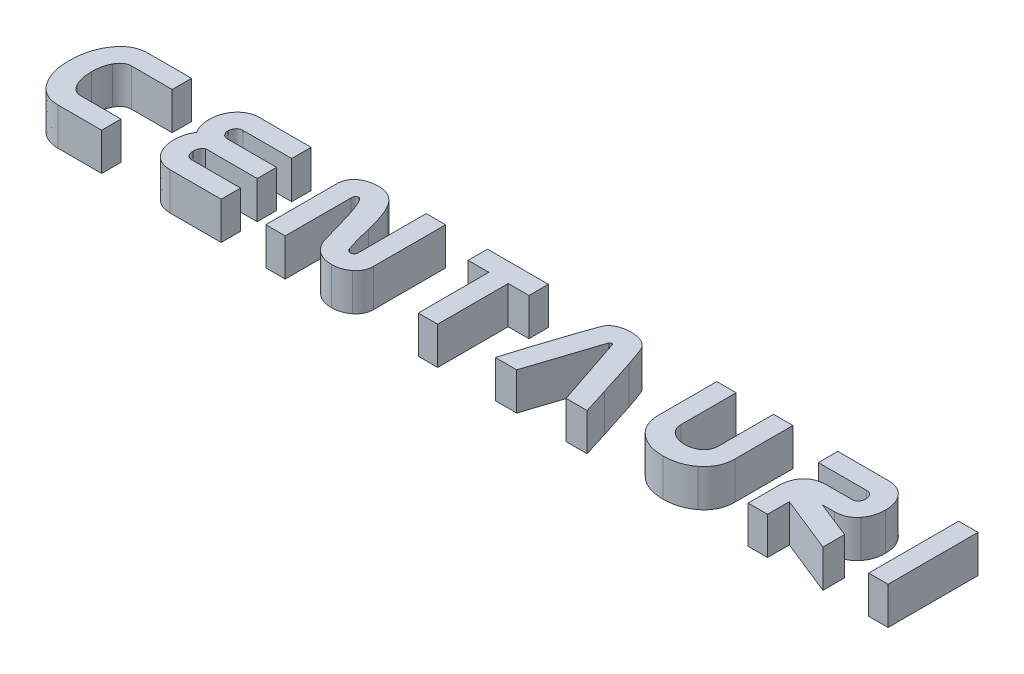
from build123d import *

# Parameters (mm, degrees)
BOSS_EXTRUDE1_DEPTH   = 5
BOSS_EXTRUDE1_2_DEPTH = 5
BOSS_EXTRUDE1_3_DEPTH = 5
BOSS_EXTRUDE1_4_DEPTH = 5
BOSS_EXTRUDE1_5_DEPTH = 5
BOSS_EXTRUDE1_6_DEPTH = 5
BOSS_EXTRUDE1_7_DEPTH = 5
SKETCH2_W             = 2.584615384
SKETCH2_H             = 12
BOSS_EXTRUDE1_8_DEPTH = 5


with BuildPart() as part:
    # Sketch2 → Boss-Extrude1 (new body)
    with BuildSketch(Plane(origin=(0, 0, 0), x_dir=(1, 0, 0), z_dir=(0, 1, 0))):
        with BuildLine():
            Line((10.583653846, 0), (4.771153846, 0))
            add(Edge.make_bspline(
                [(4.771153846, 0), (4.600577027, 0.005256158), (4.266744635, 0.015542878), (3.779986368, 0.104757843), (3.321676091, 0.249284117), (2.888640598, 0.44967442), (2.486608852, 0.712193), (2.110532552, 1.030628786), (1.76275976, 1.406766356), (1.562193503, 1.691748172), (1.459615385, 1.8375)],
                knots=[0, 0, 0, 0, 0.000511391, 0.001000833, 0.001478879, 0.00194992, 0.002427592, 0.002914759, 0.0034251, 0.003959346, 0.003959346, 0.003959346, 0.003959346], degree=3))
            add(Edge.make_bspline(
                [(1.459615385, 1.8375), (1.371116244, 1.977207082), (1.193250115, 2.257991257), (0.978414364, 2.711395344), (0.787404728, 3.18319021), (0.636476869, 3.68188656), (0.51388119, 4.202754443), (0.432733487, 4.748966419), (0.378460718, 5.317169459), (0.372344193, 5.704675421), (0.369230769, 5.901923077)],
                knots=[0, 0, 0, 0, 0.000495701, 0.000996263, 0.001502461, 0.002021636, 0.002557624, 0.003106345, 0.003676982, 0.004268581, 0.004268581, 0.004268581, 0.004268581], degree=3))
            add(Edge.make_bspline(
                [(0.369230769, 5.901923077), (0.372429228, 6.103000917), (0.378714753, 6.498153751), (0.431930375, 7.079155415), (0.517560051, 7.637252691), (0.638842238, 8.172274481), (0.794144014, 8.685947663), (0.988300396, 9.17489435), (1.212441088, 9.644085285), (1.39077351, 9.937917044), (1.479807692, 10.084615385)],
                knots=[0, 0, 0, 0, 0.000603133, 0.001185261, 0.001748677, 0.002295911, 0.002829721, 0.003356817, 0.003872873, 0.004387403, 0.004387403, 0.004387403, 0.004387403], degree=3))
            add(Edge.make_bspline(
                [(1.479807692, 10.084615385), (1.583180163, 10.237151582), (1.784074431, 10.533590735), (2.133573667, 10.925153122), (2.507077334, 11.258225235), (2.909264073, 11.528892198), (3.336322219, 11.742420666), (3.791773601, 11.892963089), (4.273222055, 11.984691886), (4.603438894, 11.994843873), (4.771153846, 12)],
                knots=[0, 0, 0, 0, 0.000552289, 0.00107332, 0.001569918, 0.002049953, 0.002523399, 0.00299774, 0.003484865, 0.003987616, 0.003987616, 0.003987616, 0.003987616], degree=3))
            Line((4.771153846, 12), (10.583653846, 12))
            Line((10.583653846, 12), (10.583653846, 9.415384615))
            Line((10.583653846, 9.415384615), (5.175, 9.415384615))
            add(Edge.make_bspline(
                [(5.175, 9.415384615), (5.095944201, 9.41167344), (4.940327859, 9.404368226), (4.712263849, 9.35787305), (4.496531906, 9.276902466), (4.296988942, 9.159047629), (4.108761042, 9.012682377), (3.93619572, 8.832200354), (3.77636789, 8.619553036), (3.684893689, 8.46162946), (3.6375, 8.379807692)],
                knots=[0, 0, 0, 0, 0.000237171, 0.000466856, 0.000695087, 0.000925152, 0.001159428, 0.001408309, 0.001671963, 0.001955435, 0.001955435, 0.001955435, 0.001955435], degree=3))
            add(Edge.make_bspline(
                [(3.6375, 8.379807692), (3.559310443, 8.218337814), (3.39818249, 7.885591194), (3.249544948, 7.331073915), (3.15507028, 6.725421927), (3.144145684, 6.303291404), (3.138461538, 6.083653846)],
                knots=[0, 0, 0, 0, 0.000537158, 0.001106941, 0.001714, 0.002372458, 0.002372458, 0.002372458, 0.002372458], degree=3))
            add(Edge.make_bspline(
                [(3.138461538, 6.083653846), (3.143678294, 5.85723427), (3.153765662, 5.419418574), (3.256034151, 4.789196535), (3.41020219, 4.205012741), (3.576462853, 3.850894878), (3.657692308, 3.677884615)],
                knots=[0, 0, 0, 0, 0.000678627, 0.001312225, 0.001911337, 0.002483662, 0.002483662, 0.002483662, 0.002483662], degree=3))
            add(Edge.make_bspline(
                [(3.657692308, 3.677884615), (3.704707297, 3.591043677), (3.795360914, 3.423598244), (3.958835405, 3.202191272), (4.12866677, 3.009880789), (4.315882401, 2.856678125), (4.512011351, 2.731914193), (4.723937386, 2.649145271), (4.945254612, 2.593907128), (5.097736923, 2.587740186), (5.175, 2.584615385)],
                knots=[0, 0, 0, 0, 0.000295895, 0.00057054, 0.000823762, 0.001063463, 0.001294016, 0.001517922, 0.001743218, 0.001974635, 0.001974635, 0.001974635, 0.001974635], degree=3))
            Line((5.175, 2.584615385), (10.583653846, 2.584615385))
            Line((10.583653846, 2.584615385), (10.583653846, 0))
        make_face()
    extrude(amount=BOSS_EXTRUDE1_DEPTH)


with BuildPart() as body_2:
    # Sketch2 → Boss-Extrude1 2 (new body)
    with BuildSketch(Plane(origin=(0, 0, 0), x_dir=(1, 0, 0), z_dir=(0, 1, 0))):
        with BuildLine():
            Line((26.534423077, 0), (19.726730769, 0))
            add(Edge.make_bspline(
                [(19.726730769, 0), (19.60248923, 0.002968336), (19.359459963, 0.008774707), (19.005021577, 0.064669346), (18.670693478, 0.158028918), (18.355254963, 0.284017483), (18.060050274, 0.44827029), (17.784807282, 0.647425556), (17.531867298, 0.88685458), (17.382573622, 1.067574739), (17.306538462, 1.159615385)],
                knots=[0, 0, 0, 0, 0.000372518, 0.000728683, 0.001073017, 0.001412091, 0.001745224, 0.002083918, 0.002428783, 0.002786719, 0.002786719, 0.002786719, 0.002786719], degree=3))
            add(Edge.make_bspline(
                [(17.306538462, 1.159615385), (17.242582037, 1.248045356), (17.114721373, 1.424833147), (16.948779194, 1.708466569), (16.815306769, 2.009830946), (16.701080367, 2.323698314), (16.612151233, 2.65172365), (16.54852392, 2.995082047), (16.510375852, 3.352970577), (16.506557523, 3.597021078), (16.504615385, 3.721153846)],
                knots=[0, 0, 0, 0, 0.000327299, 0.000654331, 0.000983544, 0.001314773, 0.00165556, 0.00200181, 0.002361463, 0.002733757, 0.002733757, 0.002733757, 0.002733757], degree=3))
            add(Edge.make_bspline(
                [(16.504615385, 3.721153846), (16.50699169, 3.833726028), (16.511672562, 4.055471908), (16.543809287, 4.381263237), (16.596231025, 4.695315192), (16.667051128, 4.998722771), (16.763298466, 5.290459103), (16.878242982, 5.570373216), (17.014292878, 5.839266035), (17.122357361, 6.007606165), (17.176730769, 6.092307692)],
                knots=[0, 0, 0, 0, 0.000337697, 0.000665199, 0.000981035, 0.001292387, 0.00159889, 0.001901555, 0.002199565, 0.002501362, 0.002501362, 0.002501362, 0.002501362], degree=3))
            add(Edge.make_bspline(
                [(17.176730769, 6.092307692), (17.122372746, 6.175074335), (17.014392854, 6.339486734), (16.878211151, 6.602584443), (16.763855887, 6.876004988), (16.667499675, 7.158962585), (16.595805743, 7.45260273), (16.544097183, 7.756234875), (16.511608569, 8.071417008), (16.506970869, 8.285498791), (16.504615385, 8.394230769)],
                knots=[0, 0, 0, 0, 0.000296905, 0.00058979, 0.000887129, 0.001185418, 0.001485557, 0.00179286, 0.00210888, 0.002435046, 0.002435046, 0.002435046, 0.002435046], degree=3))
            add(Edge.make_bspline(
                [(16.504615385, 8.394230769), (16.506517659, 8.513566887), (16.510255409, 8.748048639), (16.549116976, 9.09334719), (16.611606748, 9.425433583), (16.701761298, 9.743516569), (16.814574256, 10.047360101), (16.949604694, 10.338525679), (17.115533344, 10.613281312), (17.242671698, 10.785568518), (17.306538462, 10.872115385)],
                knots=[0, 0, 0, 0, 0.000357878, 0.00070319, 0.001040936, 0.001370604, 0.001693706, 0.00201244, 0.002332021, 0.002654608, 0.002654608, 0.002654608, 0.002654608], degree=3))
            add(Edge.make_bspline(
                [(17.306538462, 10.872115385), (17.382413893, 10.962440699), (17.53103225, 11.139362263), (17.785931716, 11.370108972), (18.060897324, 11.563220406), (18.355348409, 11.724804093), (18.670863672, 11.847691603), (19.005181091, 11.938398259), (19.359705157, 11.990432928), (19.602523395, 11.996762349), (19.726730769, 12)],
                knots=[0, 0, 0, 0, 0.000353586, 0.000692574, 0.00102791, 0.001359653, 0.001697659, 0.002041231, 0.002396963, 0.002769481, 0.002769481, 0.002769481, 0.002769481], degree=3))
            Line((19.726730769, 12), (26.534423077, 12))
            Line((26.534423077, 12), (26.534423077, 9.415384615))
            Line((26.534423077, 9.415384615), (20.038269231, 9.415384615))
            add(Edge.make_bspline(
                [(20.038269231, 9.415384615), (19.968593738, 9.4116497), (19.834335303, 9.404452853), (19.643463287, 9.34456945), (19.476016931, 9.245285152), (19.337616937, 9.107488018), (19.229591769, 8.945144965), (19.146036714, 8.767954065), (19.10013953, 8.573411461), (19.092924765, 8.439643645), (19.089230769, 8.371153846)],
                knots=[0, 0, 0, 0, 0.000208672, 0.000402091, 0.000593544, 0.000787329, 0.000982547, 0.001176161, 0.00137206, 0.001577598, 0.001577598, 0.001577598, 0.001577598], degree=3))
            add(Edge.make_bspline(
                [(19.089230769, 8.371153846), (19.091634536, 8.30548849), (19.096329834, 8.177223774), (19.144014161, 7.992102386), (19.223620252, 7.822886827), (19.329314957, 7.669355323), (19.465254852, 7.538604322), (19.634671971, 7.450070149), (19.82776287, 7.391917249), (19.96568228, 7.387133219), (20.038269231, 7.384615385)],
                knots=[0, 0, 0, 0, 0.000196683, 0.000384183, 0.000568731, 0.000755185, 0.000940902, 0.001128069, 0.001323415, 0.001540452, 0.001540452, 0.001540452, 0.001540452], degree=3))
            Line((20.038269231, 7.384615385), (26.534423077, 7.384615385))
            Line((26.534423077, 7.384615385), (26.534423077, 4.869230769))
            Line((26.534423077, 4.869230769), (26.534423077, 4.8))
            Line((26.534423077, 4.8), (19.669038462, 4.8))
            add(Edge.make_bspline(
                [(19.669038462, 4.8), (19.625801443, 4.777433078), (19.538260077, 4.731742156), (19.42315045, 4.635271596), (19.322441037, 4.515831655), (19.209481847, 4.32850192), (19.10839545, 4.056240447), (19.095718472, 3.825048162), (19.089230769, 3.706730769)],
                knots=[0, 0, 0, 0, 0.00014598, 0.000295563, 0.000446999, 0.000612732, 0.000950368, 0.001304283, 0.001304283, 0.001304283, 0.001304283], degree=3))
            add(Edge.make_bspline(
                [(19.089230769, 3.706730769), (19.091655914, 3.633408923), (19.09639846, 3.490022752), (19.143832744, 3.282143899), (19.223386831, 3.090165897), (19.327000959, 2.914402943), (19.463419164, 2.765873711), (19.632267091, 2.661302678), (19.826577732, 2.593483127), (19.96554807, 2.587661669), (20.038269231, 2.584615385)],
                knots=[0, 0, 0, 0, 0.000219705, 0.000429648, 0.000635348, 0.000841149, 0.001039097, 0.001233568, 0.001431517, 0.001648803, 0.001648803, 0.001648803, 0.001648803], degree=3))
            Line((20.038269231, 2.584615385), (26.534423077, 2.584615385))
            Line((26.534423077, 2.584615385), (26.534423077, 0))
        make_face()
    extrude(amount=BOSS_EXTRUDE1_2_DEPTH)


with BuildPart() as body_3:
    # Sketch2 → Boss-Extrude1 3 (new body)
    with BuildSketch(Plane(origin=(0, 0, 0), x_dir=(1, 0, 0), z_dir=(0, 1, 0))):
        with BuildLine():
            add(Edge.make_bspline(
                [(44.455384615, 2.388461538), (44.452620312, 2.296006881), (44.447175539, 2.113901417), (44.403783846, 1.846083233), (44.326714551, 1.591707522), (44.227474395, 1.346732915), (44.09172912, 1.11771572), (43.929171092, 0.89939778), (43.735916869, 0.694742859), (43.589386861, 0.572589054), (43.515, 0.510576923)],
                knots=[0, 0, 0, 0, 0.000277298, 0.000546187, 0.000810881, 0.001073381, 0.001337083, 0.001607084, 0.001888685, 0.002179044, 0.002179044, 0.002179044, 0.002179044], degree=3))
            add(Edge.make_bspline(
                [(43.515, 0.510576923), (43.440927528, 0.455370565), (43.293165183, 0.345243001), (43.054966146, 0.204440865), (42.807441598, 0.082989166), (42.548070365, -0.01685405), (42.277842095, -0.089445112), (41.997760742, -0.146389987), (41.707039833, -0.177231972), (41.509295141, -0.182134545), (41.409230769, -0.184615385)],
                knots=[0, 0, 0, 0, 0.000276983, 0.000552536, 0.000828616, 0.001103443, 0.001384778, 0.001667073, 0.001960142, 0.002260363, 0.002260363, 0.002260363, 0.002260363], degree=3))
            add(Edge.make_bspline(
                [(41.409230769, -0.184615385), (41.236489244, -0.178432456), (40.897370799, -0.166294407), (40.404796492, -0.056377083), (39.934581688, 0.110002147), (39.65099571, 0.280523943), (39.508269231, 0.366346154)],
                knots=[0, 0, 0, 0, 0.000517505, 0.001015943, 0.001507861, 0.002006299, 0.002006299, 0.002006299, 0.002006299], degree=3))
            add(Edge.make_bspline(
                [(39.508269231, 0.366346154), (39.430907999, 0.418397977), (39.277115131, 0.521876153), (39.072388094, 0.708031846), (38.874478811, 0.899044405), (38.703955013, 1.115808345), (38.541949473, 1.343675081), (38.403715021, 1.591766461), (38.275886344, 1.853482761), (38.209456398, 2.037752594), (38.175576923, 2.131730769)],
                knots=[0, 0, 0, 0, 0.000279331, 0.000555306, 0.00082863, 0.001103442, 0.001381115, 0.001666634, 0.001954359, 0.002253832, 0.002253832, 0.002253832, 0.002253832], degree=3))
            add(Edge.make_bspline(
                [(38.175576923, 2.131730769), (38.16586011, 2.161506666), (38.139628188, 2.241890938), (38.094007032, 2.395921871), (38.030629596, 2.612983971), (37.954381151, 2.896002813), (37.850783387, 3.239617623), (37.737377744, 3.65007647), (37.604044048, 4.122969815), (37.510107368, 4.459591263), (37.460192308, 4.638461538)],
                knots=[0, 0, 0, 0, 9.3961e-05, 0.00025366, 0.000481891, 0.000772336, 0.001132913, 0.00155847, 0.002049804, 0.002606915, 0.002606915, 0.002606915, 0.002606915], degree=3))
            add(Edge.make_bspline(
                [(37.460192308, 4.638461538), (37.413389241, 4.805857992), (37.32209462, 5.132383518), (37.183996706, 5.606268745), (37.050376616, 6.052153087), (36.924012365, 6.470891063), (36.801446393, 6.86180456), (36.678504253, 7.223419348), (36.564369113, 7.55752329), (36.487406802, 7.770294786), (36.450576923, 7.872115385)],
                knots=[0, 0, 0, 0, 0.000521446, 0.001017138, 0.001480763, 0.001917866, 0.002329315, 0.002709702, 0.003063653, 0.003388476, 0.003388476, 0.003388476, 0.003388476], degree=3))
            add(Edge.make_bspline(
                [(36.450576923, 7.872115385), (36.402410312, 7.996512604), (36.312251471, 8.22936081), (36.173063105, 8.550383411), (36.045510037, 8.82264926), (35.922487605, 9.043126677), (35.805660108, 9.214105348), (35.694280862, 9.331659594), (35.587520494, 9.407892012), (35.513874467, 9.413089129), (35.481346154, 9.415384615)],
                knots=[0, 0, 0, 0, 0.000400141, 0.000748989, 0.001049612, 0.0013015, 0.001506389, 0.001667541, 0.001789243, 0.001885522, 0.001885522, 0.001885522, 0.001885522], degree=3))
            add(Edge.make_bspline(
                [(35.481346154, 9.415384615), (35.443537025, 9.404790642), (35.372139658, 9.384785373), (35.27487457, 9.341775326), (35.195936628, 9.287376122), (35.113302075, 9.197317584), (35.05224771, 9.039675876), (35.044351346, 8.904369313), (35.04, 8.829807692)],
                knots=[0, 0, 0, 0, 0.000117705, 0.00022227, 0.000317506, 0.000403272, 0.00058546, 0.000809087, 0.000809087, 0.000809087, 0.000809087], degree=3))
            Line((35.04, 8.829807692), (35.04, 0.040384615))
            Line((35.04, 0.040384615), (32.455384615, 0.040384615))
            Line((32.455384615, 0.040384615), (32.455384615, 9.461538462))
            add(Edge.make_bspline(
                [(32.455384615, 9.461538462), (32.457385862, 9.565641378), (32.461301195, 9.769313262), (32.514272281, 10.063501833), (32.586364915, 10.342096007), (32.697387264, 10.598340706), (32.837131909, 10.837310477), (33.012114133, 11.051706898), (33.212799152, 11.253397556), (33.368059981, 11.365553055), (33.447692308, 11.423076923)],
                knots=[0, 0, 0, 0, 0.000311872, 0.000610161, 0.000894278, 0.00117343, 0.001445029, 0.001722087, 0.002001538, 0.002295783, 0.002295783, 0.002295783, 0.002295783], degree=3))
            add(Edge.make_bspline(
                [(33.447692308, 11.423076923), (33.521039699, 11.46943894), (33.668201666, 11.562458275), (33.903963059, 11.682066421), (34.15667494, 11.779537925), (34.424061241, 11.859432191), (34.706374742, 11.923386977), (35.003124038, 11.969545971), (35.315504891, 11.995096425), (35.528416452, 11.998342674), (35.637115385, 12)],
                knots=[0, 0, 0, 0, 0.000260224, 0.000522105, 0.00079155, 0.001071714, 0.001358629, 0.001659307, 0.001971926, 0.002298002, 0.002298002, 0.002298002, 0.002298002], degree=3))
            add(Edge.make_bspline(
                [(35.637115385, 12), (35.782618353, 11.99404024), (36.068225249, 11.982341862), (36.485699866, 11.902473703), (36.875926741, 11.756317936), (37.24711869, 11.563313042), (37.590821004, 11.307901851), (37.91542093, 11.0018648), (38.212059741, 10.636238038), (38.384142894, 10.363447618), (38.472692308, 10.223076923)],
                knots=[0, 0, 0, 0, 0.000436531, 0.000856864, 0.001268435, 0.001682636, 0.00210786, 0.002548612, 0.003018061, 0.003515696, 0.003515696, 0.003515696, 0.003515696], degree=3))
            add(Edge.make_bspline(
                [(38.472692308, 10.223076923), (38.532896933, 10.118113782), (38.660331916, 9.895938555), (38.828639271, 9.528013992), (39.004119436, 9.118879424), (39.168789939, 8.660933485), (39.335930096, 8.158830122), (39.504084939, 7.611320375), (39.663878869, 7.015868955), (39.766633152, 6.603052415), (39.819807692, 6.389423077)],
                knots=[0, 0, 0, 0, 0.000362831, 0.000768004, 0.001212684, 0.001698192, 0.002227265, 0.00280031, 0.003416106, 0.004076551, 0.004076551, 0.004076551, 0.004076551], degree=3))
            add(Edge.make_bspline(
                [(39.819807692, 6.389423077), (39.87621636, 6.158573765), (39.983719311, 5.718623965), (40.141553984, 5.09435595), (40.28809138, 4.539329157), (40.425333493, 4.054485307), (40.54317167, 3.635521384), (40.656582754, 3.288247046), (40.752281715, 3.007910642), (40.820034219, 2.847792984), (40.849615385, 2.777884615)],
                knots=[0, 0, 0, 0, 0.00071292, 0.001358675, 0.001931727, 0.00243495, 0.002870412, 0.003237133, 0.00353091, 0.003758576, 0.003758576, 0.003758576, 0.003758576], degree=3))
            add(Edge.make_bspline(
                [(40.849615385, 2.777884615), (40.880542241, 2.721176126), (40.938607382, 2.614705993), (41.064814723, 2.489274016), (41.218819795, 2.411275899), (41.33141431, 2.403817232), (41.389038462, 2.4)],
                knots=[0, 0, 0, 0, 0.000192946, 0.000362256, 0.000526096, 0.000697846, 0.000697846, 0.000697846, 0.000697846], degree=3))
            add(Edge.make_bspline(
                [(41.389038462, 2.4), (41.451491738, 2.408226843), (41.578976651, 2.425020171), (41.712383569, 2.530471244), (41.79372167, 2.641372516), (41.841447701, 2.745113427), (41.865928742, 2.86424225), (41.869117603, 2.947976907), (41.870769231, 2.991346154)],
                knots=[0, 0, 0, 0, 0.000186164, 0.000380013, 0.000487327, 0.000598338, 0.000719423, 0.000849519, 0.000849519, 0.000849519, 0.000849519], degree=3))
            Line((41.870769231, 2.991346154), (41.870769231, 12.023076923))
            Line((41.870769231, 12.023076923), (44.455384615, 12.023076923))
            Line((44.455384615, 12.023076923), (44.455384615, 2.388461538))
        make_face()
    extrude(amount=BOSS_EXTRUDE1_3_DEPTH)


with BuildPart() as body_4:
    # Sketch2 → Boss-Extrude1 4 (new body)
    with BuildSketch(Plane(origin=(0, 0, 0), x_dir=(1, 0, 0), z_dir=(0, 1, 0))):
        Polygon((58.190769231, 9.415384615), (55.421538462, 9.415384615), (55.421538462, 0), (52.836923077, 0), (52.836923077, 9.415384615), (50.067692308, 9.415384615), (50.067692308, 12), (58.190769231, 12), align=None)
    extrude(amount=BOSS_EXTRUDE1_4_DEPTH)


with BuildPart() as body_5:
    # Sketch2 → Boss-Extrude1 5 (new body)
    with BuildSketch(Plane(origin=(0, 0, 0), x_dir=(1, 0, 0), z_dir=(0, 1, 0))):
        with BuildLine():
            Line((75.370384615, 0), (72.557884615, 0))
            Line((72.557884615, 0), (69.451153846, 9.268269231))
            add(Edge.make_bspline(
                [(69.451153846, 9.268269231), (69.44526582, 9.290364927), (69.43386144, 9.333161558), (69.385883702, 9.381874608), (69.321651211, 9.412540023), (69.272711711, 9.414388676), (69.246346154, 9.415384615)],
                knots=[0, 0, 0, 0, 6.7527e-05, 0.000130792, 0.000197886, 0.00027625, 0.00027625, 0.00027625, 0.00027625], degree=3))
            add(Edge.make_bspline(
                [(69.246346154, 9.415384615), (69.219915114, 9.41442512), (69.169971917, 9.412612089), (69.102647549, 9.378984946), (69.04287337, 9.334310615), (69.017149958, 9.290566216), (69.004038462, 9.268269231)],
                knots=[0, 0, 0, 0, 7.8364e-05, 0.000148074, 0.000221956, 0.000298765, 0.000298765, 0.000298765, 0.000298765], degree=3))
            Line((69.004038462, 9.268269231), (65.966538462, 0))
            Line((65.966538462, 0), (63.113653846, 0))
            add(Edge.make_bspline(
                [(63.113653846, 0), (63.136604787, 0.0798446), (63.187543392, 0.257056179), (63.274576204, 0.548261636), (63.378150855, 0.892875879), (63.502828439, 1.288241077), (63.64138821, 1.737545719), (63.796536568, 2.239966349), (63.973283615, 2.793923113), (64.22422092, 3.599300874), (64.555908775, 4.621173361), (64.9462029, 5.837837083), (65.336128737, 7.017827582), (65.594285189, 7.793315691), (65.721346154, 8.175)],
                knots=[0, 0, 0, 0, 0.000249231, 0.000553158, 0.000911791, 0.001328746, 0.001796809, 0.002322348, 0.002906224, 0.003541207, 0.004853025, 0.006129242, 0.007374397, 0.008581232, 0.008581232, 0.008581232, 0.008581232], degree=3))
            add(Edge.make_bspline(
                [(65.721346154, 8.175), (65.788335329, 8.37318703), (65.914624524, 8.746812772), (66.096907795, 9.270324256), (66.254519764, 9.72621339), (66.396260998, 10.109977928), (66.513098991, 10.42638415), (66.612034384, 10.669783103), (66.683474509, 10.847690661), (66.73418774, 10.937803845), (66.754038462, 10.973076923)],
                knots=[0, 0, 0, 0, 0.000627601, 0.001183165, 0.001663035, 0.002074606, 0.002410537, 0.002674617, 0.002863245, 0.002984571, 0.002984571, 0.002984571, 0.002984571], degree=3))
            add(Edge.make_bspline(
                [(66.754038462, 10.973076923), (66.817086053, 11.053077531), (66.945187031, 11.215623887), (67.184349277, 11.423255577), (67.464351809, 11.59704258), (67.777311186, 11.742956346), (68.118729727, 11.855543129), (68.478506843, 11.940575901), (68.853657962, 11.989412467), (69.108710478, 11.99644407), (69.237692308, 12)],
                knots=[0, 0, 0, 0, 0.000305075, 0.000619855, 0.000943973, 0.001291111, 0.001653254, 0.002020598, 0.002398791, 0.002785716, 0.002785716, 0.002785716, 0.002785716], degree=3))
            add(Edge.make_bspline(
                [(69.237692308, 12), (69.366678225, 11.996482744), (69.620785387, 11.989553617), (69.994009073, 11.940551413), (70.350965042, 11.855634388), (70.69015422, 11.742328787), (71.002439658, 11.597133451), (71.28223705, 11.423124661), (71.52157417, 11.216449391), (71.647850002, 11.053183781), (71.709807692, 10.973076923)],
                knots=[0, 0, 0, 0, 0.000386926, 0.000762258, 0.001126794, 0.001486204, 0.001833342, 0.00215746, 0.002472241, 0.002775468, 0.002775468, 0.002775468, 0.002775468], degree=3))
            add(Edge.make_bspline(
                [(71.709807692, 10.973076923), (71.731582077, 10.937838542), (71.787521806, 10.847308979), (71.867459945, 10.669254344), (71.967700141, 10.423384267), (72.08773707, 10.10937742), (72.229447557, 9.727779661), (72.390410717, 9.2775432), (72.57217751, 8.759603156), (72.696758006, 8.3905264), (72.762692308, 8.195192308)],
                knots=[0, 0, 0, 0, 0.000124173, 0.000319007, 0.000584172, 0.000921129, 0.001327287, 0.001805402, 0.002355518, 0.002973997, 0.002973997, 0.002973997, 0.002973997], degree=3))
            add(Edge.make_bspline(
                [(72.762692308, 8.195192308), (72.807803614, 8.058627351), (72.903748567, 7.76817426), (73.058481835, 7.305631097), (73.223549721, 6.787278578), (73.409073669, 6.215458866), (73.611380621, 5.589926737), (73.827006926, 4.909884599), (74.058252016, 4.17511556), (74.217542583, 3.667321096), (74.300192308, 3.403846154)],
                knots=[0, 0, 0, 0, 0.000431469, 0.00091767, 0.001463191, 0.00206344, 0.002721164, 0.003435484, 0.004203659, 0.005032061, 0.005032061, 0.005032061, 0.005032061], degree=3))
            add(Edge.make_bspline(
                [(74.300192308, 3.403846154), (74.399943629, 3.084537127), (74.59200641, 2.469734452), (74.873118754, 1.58390946), (75.129169197, 0.768310231), (75.292499496, 0.248076739), (75.370384615, 0)],
                knots=[0, 0, 0, 0, 0.001003581, 0.001932311, 0.002788074, 0.003568122, 0.003568122, 0.003568122, 0.003568122], degree=3))
        make_face()
    extrude(amount=BOSS_EXTRUDE1_5_DEPTH)


with BuildPart() as body_6:
    # Sketch2 → Boss-Extrude1 6 (new body)
    with BuildSketch(Plane(origin=(0, 0, 0), x_dir=(1, 0, 0), z_dir=(0, 1, 0))):
        with BuildLine():
            add(Edge.make_bspline(
                [(90.830769231, 4.272115385), (90.825862631, 4.101624608), (90.816276915, 3.768547499), (90.738959935, 3.282982694), (90.616051192, 2.823438113), (90.438754382, 2.390127008), (90.208731779, 1.984021403), (89.930114701, 1.604481915), (89.601895754, 1.250597342), (89.349757074, 1.045165195), (89.221153846, 0.940384615)],
                knots=[0, 0, 0, 0, 0.000511237, 0.000998771, 0.001471117, 0.001935549, 0.002399255, 0.002867745, 0.003345321, 0.003842489, 0.003842489, 0.003842489, 0.003842489], degree=3))
            add(Edge.make_bspline(
                [(89.221153846, 0.940384615), (89.098628678, 0.850624748), (88.85297267, 0.670661307), (88.457397646, 0.441758906), (88.04290492, 0.24628119), (87.606399047, 0.091234717), (87.151349213, -0.032752633), (86.675078436, -0.122946398), (86.179049354, -0.174760292), (85.841465964, -0.181298308), (85.670192308, -0.184615385)],
                knots=[0, 0, 0, 0, 0.000455386, 0.000913022, 0.001368554, 0.001828431, 0.002300777, 0.002782232, 0.003281095, 0.003794848, 0.003794848, 0.003794848, 0.003794848], degree=3))
            add(Edge.make_bspline(
                [(85.670192308, -0.184615385), (85.503702805, -0.181438349), (85.176620491, -0.175196802), (84.695424621, -0.121585874), (84.234090335, -0.036436058), (83.792954989, 0.085082637), (83.37363964, 0.241754357), (82.972284395, 0.429972187), (82.590325925, 0.65332184), (82.355081938, 0.831255683), (82.2375, 0.920192308)],
                knots=[0, 0, 0, 0, 0.000499339, 0.000980992, 0.001450573, 0.001905465, 0.002351798, 0.002791822, 0.003234101, 0.003676078, 0.003676078, 0.003676078, 0.003676078], degree=3))
            add(Edge.make_bspline(
                [(82.2375, 0.920192308), (82.112824564, 1.025139222), (81.867747279, 1.231435711), (81.548382766, 1.584487509), (81.278425595, 1.964156331), (81.056946372, 2.371635109), (80.885624442, 2.807709819), (80.766706009, 3.27192257), (80.687625572, 3.762686966), (80.680545774, 4.09967851), (80.676923077, 4.272115385)],
                knots=[0, 0, 0, 0, 0.000488455, 0.000960167, 0.001423594, 0.001883109, 0.002348069, 0.002825244, 0.00331848, 0.003835342, 0.003835342, 0.003835342, 0.003835342], degree=3))
            Line((80.676923077, 4.272115385), (80.676923077, 12))
            Line((80.676923077, 12), (83.261538462, 12))
            Line((83.261538462, 12), (83.261538462, 4.641346154))
            add(Edge.make_bspline(
                [(83.261538462, 4.641346154), (83.263529937, 4.564280511), (83.267462909, 4.412083321), (83.30529681, 4.18991397), (83.369832329, 3.98020172), (83.457122392, 3.781247099), (83.56954533, 3.594161815), (83.707250761, 3.419021297), (83.86967349, 3.255872014), (83.993987566, 3.161077463), (84.057692308, 3.1125)],
                knots=[0, 0, 0, 0, 0.000231058, 0.000456316, 0.000673488, 0.000887883, 0.001106543, 0.0013264, 0.00155485, 0.001794967, 0.001794967, 0.001794967, 0.001794967], degree=3))
            add(Edge.make_bspline(
                [(84.057692308, 3.1125), (84.183027133, 3.03070962), (84.434929039, 2.866324722), (84.865329143, 2.70591203), (85.328406859, 2.599488064), (85.651275822, 2.589666181), (85.817307692, 2.584615385)],
                knots=[0, 0, 0, 0, 0.000447711, 0.000899823, 0.001369457, 0.001866625, 0.001866625, 0.001866625, 0.001866625], degree=3))
            add(Edge.make_bspline(
                [(85.817307692, 2.584615385), (85.976537556, 2.590137144), (86.28459578, 2.60081996), (86.726226338, 2.699585045), (87.132993238, 2.855448551), (87.369797035, 3.013665967), (87.4875, 3.092307692)],
                knots=[0, 0, 0, 0, 0.000477018, 0.000922875, 0.001351404, 0.001774902, 0.001774902, 0.001774902, 0.001774902], degree=3))
            add(Edge.make_bspline(
                [(87.4875, 3.092307692), (87.548530914, 3.139761289), (87.66817758, 3.232790614), (87.820742313, 3.397133222), (87.952911321, 3.57118191), (88.060315792, 3.76041186), (88.143644489, 3.963167132), (88.205080939, 4.177740715), (88.23981782, 4.405591778), (88.244005832, 4.561421645), (88.246153846, 4.641346154)],
                knots=[0, 0, 0, 0, 0.000231579, 0.000453994, 0.00067034, 0.000886089, 0.001104655, 0.001326545, 0.001554193, 0.001793893, 0.001793893, 0.001793893, 0.001793893], degree=3))
            Line((88.246153846, 4.641346154), (88.246153846, 12))
            Line((88.246153846, 12), (90.830769231, 12))
            Line((90.830769231, 12), (90.830769231, 4.272115385))
        make_face()
    extrude(amount=BOSS_EXTRUDE1_6_DEPTH)


with BuildPart() as body_7:
    # Sketch2 → Boss-Extrude1 7 (new body)
    with BuildSketch(Plane(origin=(0, 0, 0), x_dir=(1, 0, 0), z_dir=(0, 1, 0))):
        with BuildLine():
            Line((106.888269231, -0.046153846), (99.396923077, 2.953846154))
            Line((99.396923077, 2.953846154), (99.396923077, 0.040384615))
            Line((99.396923077, 0.040384615), (96.812307692, 0.040384615))
            Line((96.812307692, 0.040384615), (96.812307692, 4.026923077))
            add(Edge.make_bspline(
                [(96.812307692, 4.026923077), (96.814737962, 4.144286037), (96.819468279, 4.37272327), (96.850089576, 4.707732915), (96.908860846, 5.024596389), (96.985977543, 5.324689294), (97.083690993, 5.608709421), (97.20918857, 5.872892085), (97.351887833, 6.124157837), (97.467296886, 6.276171439), (97.524807692, 6.351923077)],
                knots=[0, 0, 0, 0, 0.000352112, 0.000685357, 0.001007867, 0.001317812, 0.001614311, 0.001907252, 0.002194209, 0.002479247, 0.002479247, 0.002479247, 0.002479247], degree=3))
            add(Edge.make_bspline(
                [(97.524807692, 6.351923077), (97.595823643, 6.434681569), (97.737082067, 6.599297181), (97.9846044, 6.80990105), (98.256802862, 6.987333637), (98.551272939, 7.135575454), (98.87250567, 7.247676743), (99.216585068, 7.32859524), (99.586109763, 7.37386019), (99.84007251, 7.380957517), (99.970961538, 7.384615385)],
                knots=[0, 0, 0, 0, 0.000326765, 0.00064997, 0.000970799, 0.001299759, 0.001636419, 0.001989063, 0.002358305, 0.002750994, 0.002750994, 0.002750994, 0.002750994], degree=3))
            Line((99.970961538, 7.384615385), (103.247884615, 7.384615385))
            add(Edge.make_bspline(
                [(103.247884615, 7.384615385), (103.319461081, 7.387291136), (103.456325443, 7.392407553), (103.64944015, 7.449436109), (103.817412425, 7.541848488), (103.953757834, 7.672920931), (104.062930645, 7.824851007), (104.141969224, 7.995099323), (104.189626659, 8.179140556), (104.194464267, 8.306447547), (104.196923077, 8.371153846)],
                knots=[0, 0, 0, 0, 0.000214162, 0.000409508, 0.00059807, 0.000783787, 0.000971907, 0.001156455, 0.001343955, 0.001537761, 0.001537761, 0.001537761, 0.001537761], degree=3))
            add(Edge.make_bspline(
                [(104.196923077, 8.371153846), (104.194232529, 8.439649093), (104.188983465, 8.573278374), (104.145898259, 8.765175229), (104.070422385, 8.939854233), (103.996986839, 9.039671503), (103.960384615, 9.089423077)],
                knots=[0, 0, 0, 0, 0.000205315, 0.000400555, 0.00058654, 0.000771358, 0.000771358, 0.000771358, 0.000771358], degree=3))
            add(Edge.make_bspline(
                [(103.960384615, 9.089423077), (103.914328574, 9.138847265), (103.823363138, 9.23646514), (103.651335734, 9.342425394), (103.455919157, 9.40464948), (103.318537958, 9.411738715), (103.247884615, 9.415384615)],
                knots=[0, 0, 0, 0, 0.000201944, 0.00039886, 0.000598649, 0.000810192, 0.000810192, 0.000810192, 0.000810192], degree=3))
            Line((103.247884615, 9.415384615), (96.812307692, 9.415384615))
            Line((96.812307692, 9.415384615), (96.812307692, 12))
            Line((96.812307692, 12), (103.579615385, 12))
            add(Edge.make_bspline(
                [(103.579615385, 12), (103.702865862, 11.996780462), (103.943779468, 11.990487339), (104.296317549, 11.938079555), (104.627585074, 11.848141118), (104.941480391, 11.726961225), (105.232590442, 11.566519118), (105.507153678, 11.375228231), (105.759918085, 11.146051509), (105.907553623, 10.970093404), (105.9825, 10.880769231)],
                knots=[0, 0, 0, 0, 0.000369636, 0.000722516, 0.001066088, 0.001397668, 0.001729411, 0.002060728, 0.002399716, 0.002749231, 0.002749231, 0.002749231, 0.002749231], degree=3))
            add(Edge.make_bspline(
                [(105.9825, 10.880769231), (106.046787945, 10.795441341), (106.174934686, 10.62535516), (106.335319473, 10.348350754), (106.475158075, 10.059765751), (106.587857281, 9.755413079), (106.673654582, 9.436481051), (106.737553829, 9.104019857), (106.775786153, 8.75667053), (106.779598472, 8.520288617), (106.781538462, 8.4)],
                knots=[0, 0, 0, 0, 0.000320244, 0.000638351, 0.000958322, 0.001281425, 0.001610322, 0.001948068, 0.002296247, 0.002657009, 0.002657009, 0.002657009, 0.002657009], degree=3))
            add(Edge.make_bspline(
                [(106.781538462, 8.4), (106.779621077, 8.280667653), (106.775853636, 8.046193312), (106.737207193, 7.700841068), (106.674151536, 7.370115653), (106.587289707, 7.052435246), (106.475222747, 6.74887077), (106.335302414, 6.460307662), (106.174938973, 6.183297538), (106.046789377, 6.013212122), (105.9825, 5.927884615)],
                knots=[0, 0, 0, 0, 0.000357878, 0.00070319, 0.001040936, 0.001367051, 0.001690154, 0.002010125, 0.002328231, 0.002648476, 0.002648476, 0.002648476, 0.002648476], degree=3))
            add(Edge.make_bspline(
                [(105.9825, 5.927884615), (105.907750234, 5.837397517), (105.760949666, 5.659690504), (105.506104743, 5.431045098), (105.233684386, 5.235683018), (104.940666753, 5.076859936), (104.62833701, 4.950966808), (104.296203878, 4.862194391), (103.943809797, 4.809439568), (103.702876126, 4.8031948), (103.579615385, 4.8)],
                knots=[0, 0, 0, 0, 0.000351687, 0.000690675, 0.001023657, 0.001355401, 0.001688046, 0.002031618, 0.002384497, 0.002754134, 0.002754134, 0.002754134, 0.002754134], degree=3))
            Line((103.579615385, 4.8), (101.944038462, 4.8))
            Line((101.944038462, 4.8), (106.888269231, 2.85))
            Line((106.888269231, 2.85), (106.888269231, -0.046153846))
        make_face()
    extrude(amount=BOSS_EXTRUDE1_7_DEPTH)


with BuildPart() as body_8:
    # Sketch2 → Boss-Extrude1 8 (new body)
    with BuildSketch(Plane(origin=(0, 0, 0), x_dir=(1, 0, 0), z_dir=(0, 1, 0))):
        with Locations((114.24, 6)):
            Rectangle(SKETCH2_W, SKETCH2_H)
    extrude(amount=BOSS_EXTRUDE1_8_DEPTH)


solid = Compound([part.part, body_2.part, body_3.part, body_4.part, body_5.part, body_6.part, body_7.part, body_8.part])
